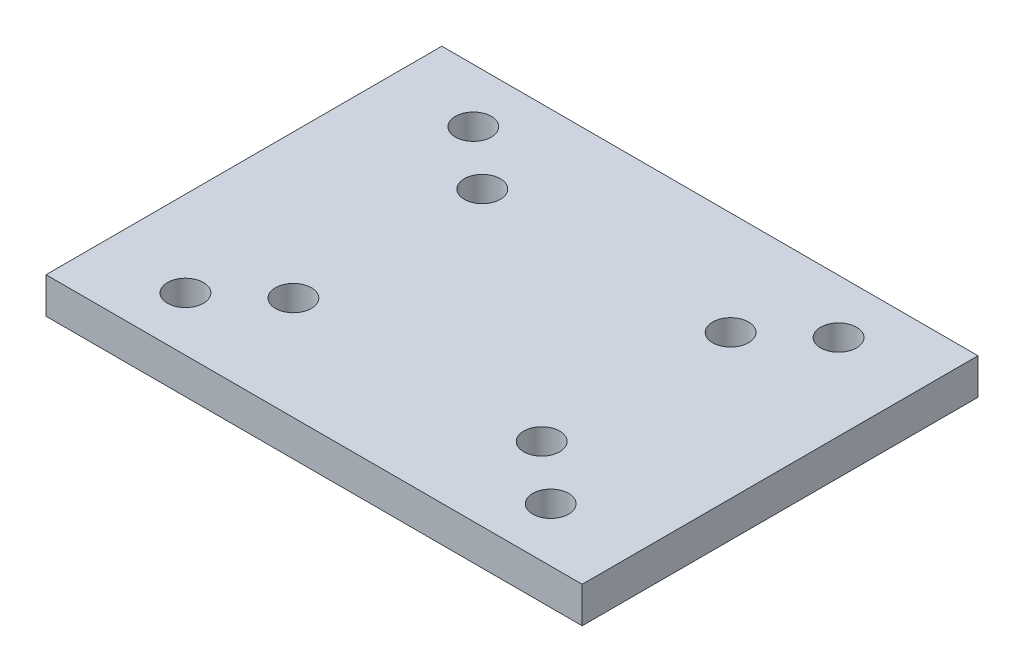
from build123d import *

# Parameters (mm, degrees)
SKETCH1_W           = 29.8
SKETCH1_H           = 22
SKETCH1_R           = 1
BOSS_EXTRUDE1_DEPTH = 2
SKETCH2_R           = 1
CUT_EXTRUDE1_DEPTH  = 10


with BuildPart() as part:
    # Sketch1 → Boss-Extrude1 (new body)
    with BuildSketch(Plane(origin=(0, 0, 0), x_dir=(1, 0, 0), z_dir=(0, 1, 0))):
        Rectangle(SKETCH1_W, SKETCH1_H)
        with Locations((10.15, 8)):
            Circle(SKETCH1_R, mode=Mode.SUBTRACT)
        with Locations((10.15, -8)):
            Circle(SKETCH1_R, mode=Mode.SUBTRACT)
        with Locations((-10.15, -8)):
            Circle(SKETCH1_R, mode=Mode.SUBTRACT)
        with Locations((-10.15, 8)):
            Circle(SKETCH1_R, mode=Mode.SUBTRACT)
    extrude(amount=BOSS_EXTRUDE1_DEPTH)

    # Sketch2 → Cut-Extrude1 (cut)
    with BuildSketch(Plane.XZ):
        with Locations((6.9, -5.25)):
            Circle(SKETCH2_R)
        with Locations((-6.9, -5.25)):
            Circle(SKETCH2_R)
    cut_extrude1 = extrude(amount=-CUT_EXTRUDE1_DEPTH, mode=Mode.SUBTRACT)

    # Mirror1: Cut-Extrude1 across plane
    add(cut_extrude1.mirror(Plane(origin=(0, 0, 0), x_dir=(1, 0, 0), z_dir=(0, 0, -1))), mode=Mode.SUBTRACT)


solid = part.part
